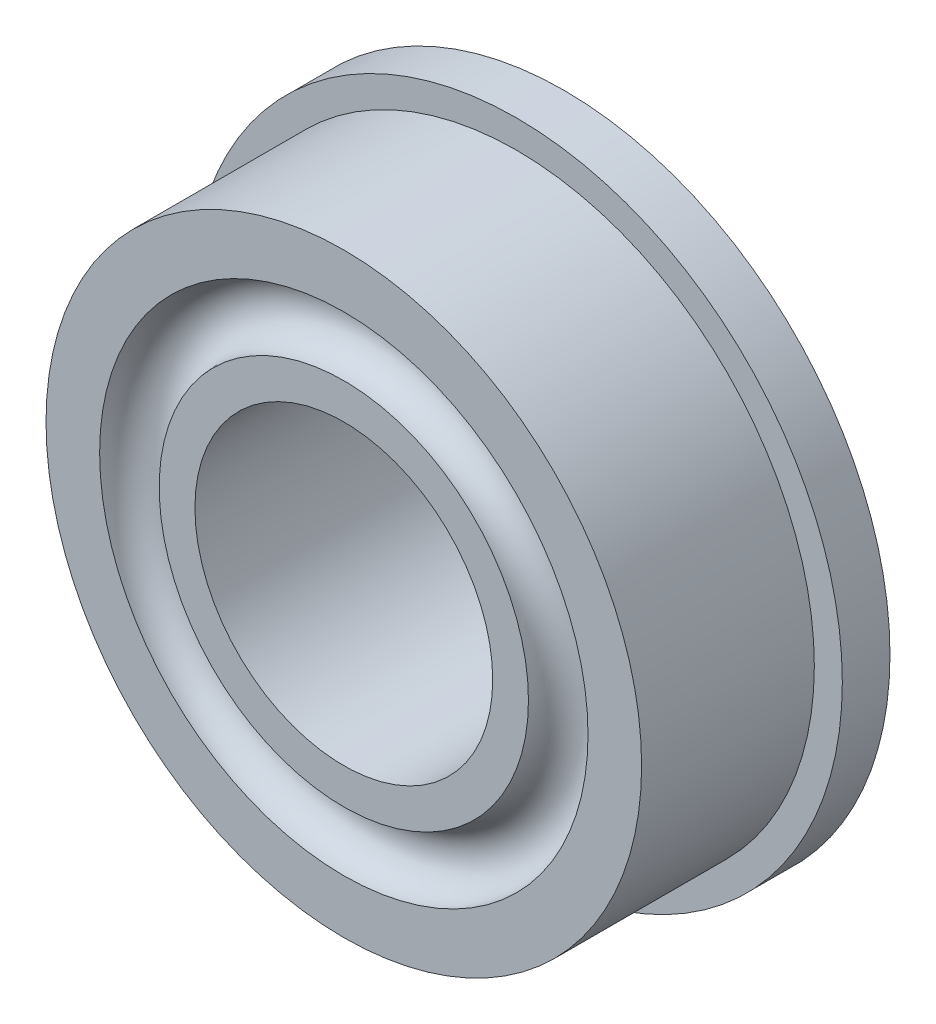
from build123d import *

# Parameters (mm, degrees)
SKETCH1_R           = 6.9469
SKETCH1_R_2         = 3.175
BOSS_EXTRUDE1_DEPTH = 1.016
SKETCH2_R           = 6.35
SKETCH2_R_2         = 3.175
BOSS_EXTRUDE2_DEPTH = 3.683


with BuildPart() as part:
    # Sketch1 → Boss-Extrude1 (new body)
    with BuildSketch(Plane.XY):
        Circle(SKETCH1_R)
        Circle(SKETCH1_R_2, mode=Mode.SUBTRACT)
    extrude(amount=BOSS_EXTRUDE1_DEPTH)

    # Sketch2 → Boss-Extrude2 (add)
    with BuildSketch(Plane.XY.offset(1.016)):
        Circle(SKETCH2_R)
        Circle(SKETCH2_R_2, mode=Mode.SUBTRACT)
    extrude(amount=BOSS_EXTRUDE2_DEPTH)

    # Sketch7 → Cut-Revolve2 (revolve, cut)
    with BuildSketch(Plane(origin=(0, 0, 0), x_dir=(0, 0, -1), z_dir=(1, 0, 0))):
        with BuildLine():
            Line((-4.699, 5.207), (-4.699, 3.937))
            ThreePointArc((-4.699, 3.937), (-4.064, 4.572), (-4.699, 5.207))
        make_face()
        with BuildLine():
            Line((0, 5.207), (0, 3.937))
            ThreePointArc((0, 3.937), (-0.635, 4.572), (0, 5.207))
        make_face()
    revolve(axis=Axis((0, 0, 4.699), (0, 0, -1)), mode=Mode.SUBTRACT)


solid = part.part
